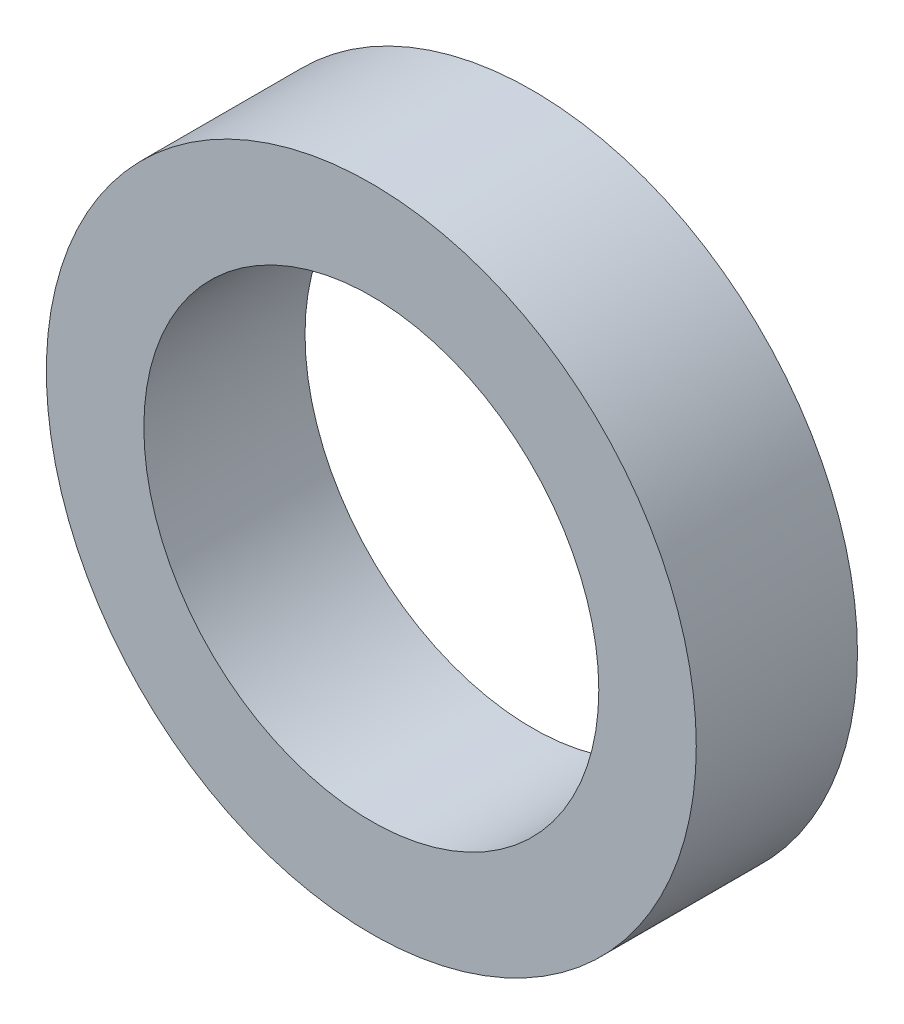
from build123d import *

# Parameters (mm, degrees)
SKETCH1_R           = 15.875
SKETCH1_R_2         = 11.1125
BOSS_EXTRUDE1_DEPTH = 3.937


with BuildPart() as part:
    # Sketch1 → Boss-Extrude1 (new body, symmetric)
    with BuildSketch(Plane.XY):
        Circle(SKETCH1_R)
        Circle(SKETCH1_R_2, mode=Mode.SUBTRACT)
    extrude(amount=BOSS_EXTRUDE1_DEPTH, both=True)


solid = part.part
